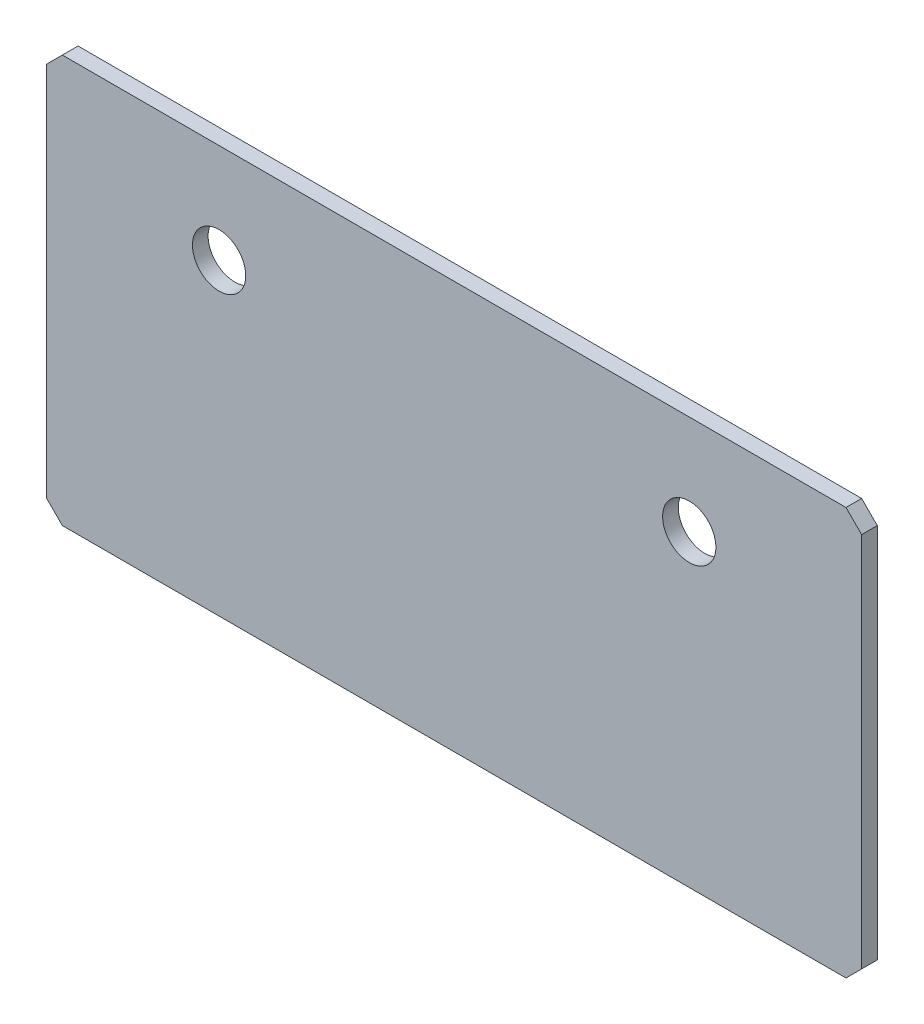
from build123d import *

# Parameters (mm, degrees)
SKETCH1_W           = 52
SKETCH1_H           = 26
SKETCH1_R           = 1.7
BOSS_EXTRUDE1_DEPTH = 1
CHAMFER1_SIZE       = 1


with BuildPart() as part:
    # Sketch1 → Boss-Extrude1 (new body)
    with BuildSketch(Plane.XY):
        with Locations((26, -13)):
            Rectangle(SKETCH1_W, SKETCH1_H)
        with Locations((11, -6.344)):
            Circle(SKETCH1_R, mode=Mode.SUBTRACT)
        with Locations((41, -6.344)):
            Circle(SKETCH1_R, mode=Mode.SUBTRACT)
    extrude(amount=BOSS_EXTRUDE1_DEPTH)

    # Chamfer1
    chamfer1_edges = [part.edges().sort_by_distance(p)[0] for p in [
        (0, 0, 0.5),
        (52, 0, 0.5),
        (52, -26, 0.5),
        (0, -26, 0.5),
    ]]
    chamfer(chamfer1_edges, length=CHAMFER1_SIZE)


solid = part.part
